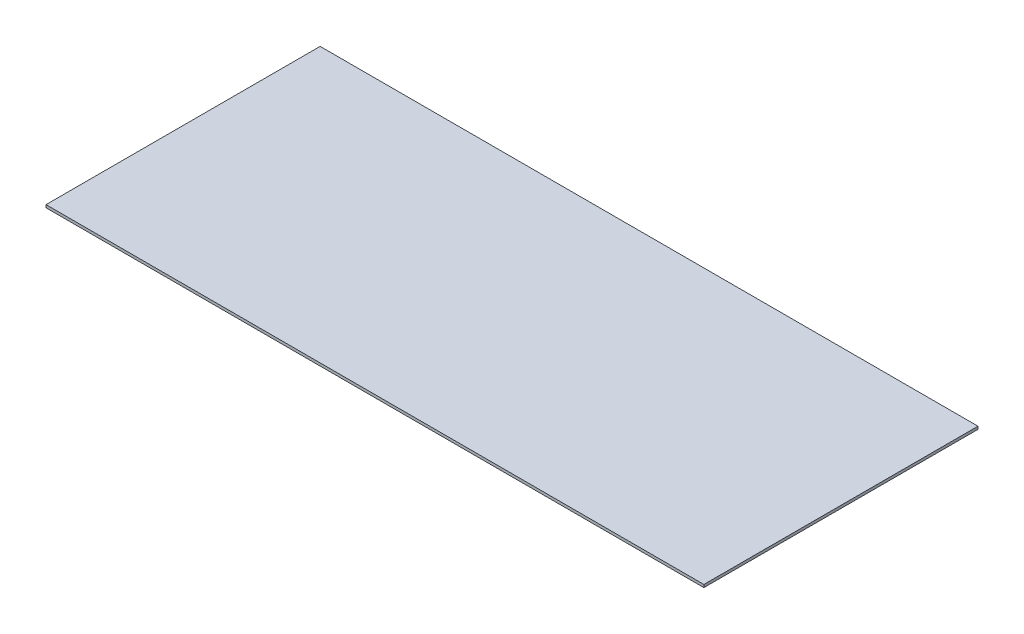
from build123d import *

# Parameters (mm, degrees)
ESQUISSE1_W        = 1200
ESQUISSE1_H        = 5
BOSS_EXTRU_1_DEPTH = 500


with BuildPart() as part:
    # Esquisse1 → Boss.-Extru.1 (new body)
    with BuildSketch(Plane.XY):
        with Locations((0, 2.5)):
            Rectangle(ESQUISSE1_W, ESQUISSE1_H)
    extrude(amount=BOSS_EXTRU_1_DEPTH)


solid = part.part
